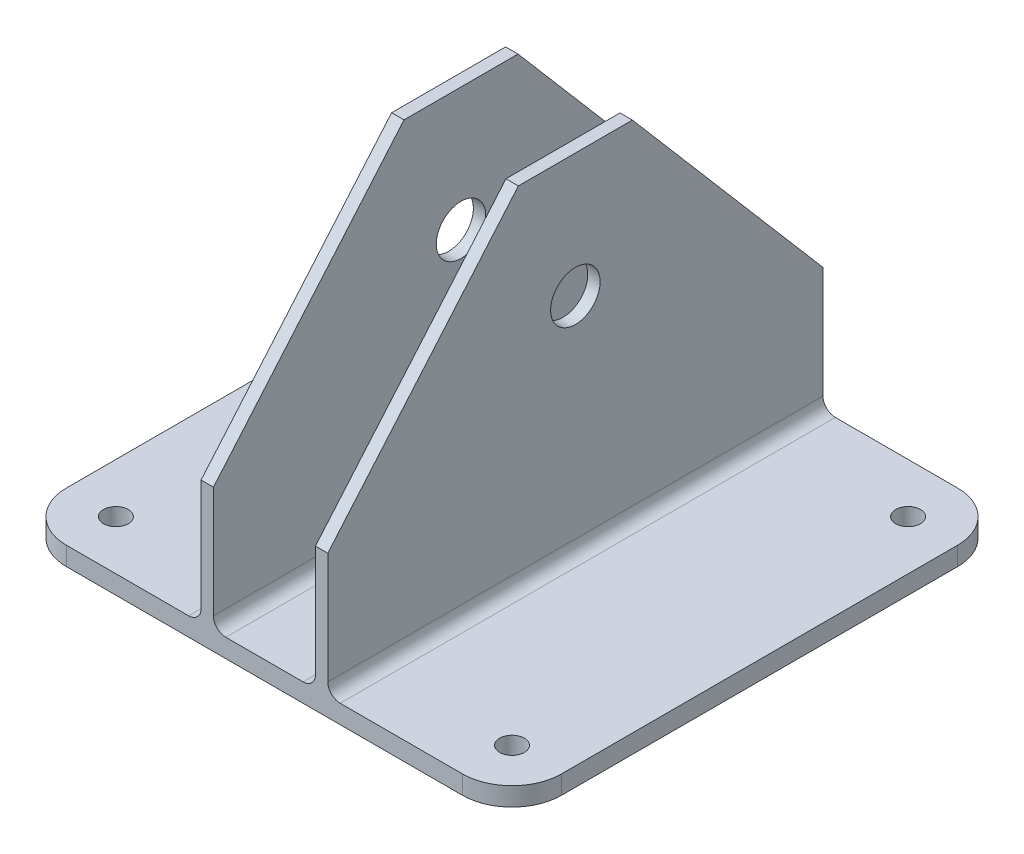
from build123d import *

# Parameters (mm, degrees)
SKETCH1_W               = 127
SKETCH1_H               = 127
BOSS_EXTRUDE1_DEPTH     = 4.7625
SKETCH2_W               = 3.175
SKETCH2_H               = 127
BOSS_EXTRUDE2_DEPTH     = 88.9
SKETCH3_R               = 6.35
CUT_EXTRUDE1_DEPTH      = 48.244
CUT_EXTRUDE1_DEPTH_BACK = 80.756
FILLET1_R               = 3.175
CHAMFER1_SIZE           = 25.4
CUT_EXTRUDE4_START      = -5.7625
SKETCH4_R               = 3.175
CUT_EXTRUDE4_DEPTH      = 95.6625
FILLET5_R               = 12.7
CUT_EXTRUDE5_DEPTH      = 48.244
CUT_EXTRUDE5_DEPTH_BACK = 80.756


with BuildPart() as part:
    # Sketch1 → Boss-Extrude1 (new body)
    with BuildSketch(Plane(origin=(0, 0, 0), x_dir=(1, 0, 0), z_dir=(0, 1, 0))):
        Rectangle(SKETCH1_W, SKETCH1_H)
    extrude(amount=BOSS_EXTRUDE1_DEPTH)

    # Sketch2 → Boss-Extrude2 (add)
    with BuildSketch(Plane(origin=(0, 4.7625, 0), x_dir=(1, 0, 0), z_dir=(0, 1, 0))):
        with Locations((-14.6685, 0)):
            Rectangle(SKETCH2_W, SKETCH2_H)
        with Locations((14.6685, 0)):
            Rectangle(SKETCH2_W, SKETCH2_H)
    extrude(amount=BOSS_EXTRUDE2_DEPTH)

    # Sketch3 → Cut-Extrude1 (cut, two sides)
    with BuildSketch(Plane.ZY.offset(16.256)) as cut_extrude1_sk:
        with Locations((0, 61.9125)):
            Circle(SKETCH3_R)
    extrude(amount=CUT_EXTRUDE1_DEPTH, mode=Mode.SUBTRACT)
    extrude(cut_extrude1_sk.sketch, amount=-CUT_EXTRUDE1_DEPTH_BACK, mode=Mode.SUBTRACT)

    # Fillet1
    fillet1_edges = [part.edges().sort_by_distance(p)[0] for p in [
        (-16.256, 4.7625, 0),
        (-13.081, 4.7625, 0),
        (13.081, 4.7625, 0),
        (16.256, 4.7625, 0),
    ]]
    fillet(fillet1_edges, radius=FILLET1_R)

    # Chamfer1
    chamfer1_edges = [part.edges().sort_by_distance(p)[0] for p in [
        (-14.6685, 93.6625, 63.5),
        (-14.6685, 93.6625, -63.5),
        (14.6685, 93.6625, 63.5),
        (14.6685, 93.6625, -63.5),
    ]]
    chamfer(chamfer1_edges, length=CHAMFER1_SIZE)

    # Sketch4 → Cut-Extrude4 (cut)
    with BuildSketch(Plane(origin=(0, 4.7625, 0), x_dir=(1, 0, 0), z_dir=(0, 1, 0)).offset(CUT_EXTRUDE4_START)):
        with Locations((-50.8, -50.8)):
            Circle(SKETCH4_R)
        with Locations((-50.8, 50.8)):
            Circle(SKETCH4_R)
    cut_extrude4 = extrude(amount=CUT_EXTRUDE4_DEPTH, mode=Mode.SUBTRACT)

    # Mirror2: Cut-Extrude4 across plane
    add(cut_extrude4.mirror(Plane.ZY), mode=Mode.SUBTRACT)

    # Fillet5
    fillet5_edges = [part.edges().sort_by_distance(p)[0] for p in [
        (-63.5, 2.38125, -63.5),
        (63.5, 2.38125, -63.5),
        (63.5, 2.38125, 63.5),
        (-63.5, 2.38125, 63.5),
    ]]
    fillet(fillet5_edges, radius=FILLET5_R)

    # Sketch7 → Cut-Extrude5 (cut, two sides)
    with BuildSketch(Plane.ZY.offset(16.256)) as cut_extrude5_sk:
        Polygon((-63.5, 36.5125), (-14.62430355, 93.6625), (-38.1, 93.6625), (-63.5, 68.2625), align=None)
        Polygon((38.1, 93.6625), (14.62430355, 93.6625), (63.5, 36.5125), (63.5, 68.2625), align=None)
    extrude(amount=CUT_EXTRUDE5_DEPTH, mode=Mode.SUBTRACT)
    extrude(cut_extrude5_sk.sketch, amount=-CUT_EXTRUDE5_DEPTH_BACK, mode=Mode.SUBTRACT)


solid = part.part
